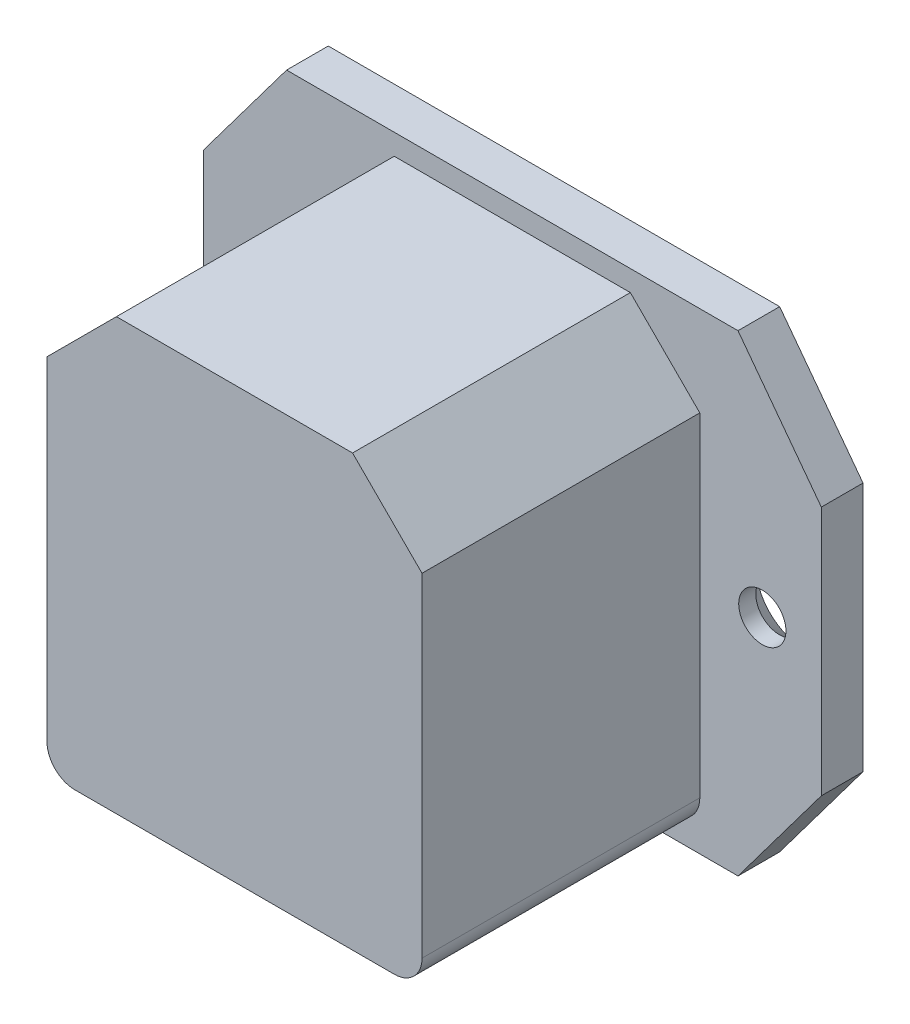
from build123d import *

# Parameters (mm, degrees)
SKIZZE1_W                                   = 27
SKIZZE1_H                                   = 31
AUFSATZ_LINEAR_AUSTRAGEN1_DEPTH             = 20
AUFSATZ_LINEAR_AUSTRAGEN2_DEPTH             = 3
FORMSENKUNG_F_R_M3_SENKSCHRAUBE_MIT_2_COUNT = 2
FORMSENKUNG_F_R_M3_SENKSCHRAUBE_MIT_2_PITCH = 36
SCHNITT_LINEAR_AUSTRAGEN1_DEPTH             = 18
FASE1_SIZE                                  = 5
VERRUNDUNG1_R                               = 2


with BuildPart() as part:
    # Skizze1 → Aufsatz-Linear austragen1 (new body)
    with BuildSketch(Plane.XY):
        Rectangle(SKIZZE1_W, SKIZZE1_H)
    extrude(amount=AUFSATZ_LINEAR_AUSTRAGEN1_DEPTH)

    # Skizze2 → Aufsatz-Linear austragen2 (add)
    with BuildSketch(Plane.XY):
        Polygon((16.25, 17), (-16.25, 17), (-22.25, 9), (-22.25, -9), (-16.25, -17), (16.25, -17), (22.25, -9), (22.25, 9), align=None)
    extrude(amount=-AUFSATZ_LINEAR_AUSTRAGEN2_DEPTH)

    # Skizze3 → Formsenkung für M3 Senkschraube mit Innensechskant1 (revolve, cut)
    with BuildSketch(Plane(origin=(18, 0, -3), x_dir=(0, 1, 0), z_dir=(1, 0, 0))):
        Polygon((0, 0), (0, 3), (1.7, 3), (1.7, 1.77), (3.47, 0), align=None)
    formsenkung_f_r_m3_senkschraube_mit_inne = revolve(axis=Axis((18, 0, -9.35), (0, 0, 1)), mode=Mode.SUBTRACT)

    # Formsenkung f_r M3 Senkschraube mit  2: Formsenkung für M3 Senkschraube mit Innensechskant1 ×2
    with Locations(*[(-i * FORMSENKUNG_F_R_M3_SENKSCHRAUBE_MIT_2_PITCH, 0, 0) for i in range(1, FORMSENKUNG_F_R_M3_SENKSCHRAUBE_MIT_2_COUNT)]):
        add(formsenkung_f_r_m3_senkschraube_mit_inne, mode=Mode.SUBTRACT)

    # Skizze5 → Schnitt-Linear austragen1 (cut)
    with BuildSketch(Plane(origin=(0, 0, -3), x_dir=(-1, 0, 0), z_dir=(0, 0, -1))):
        Polygon((7.25, 14), (-7.25, 14), (-12.25, 9), (-12.25, -2), (12.25, -2), (12.25, 9), align=None)
    extrude(amount=-SCHNITT_LINEAR_AUSTRAGEN1_DEPTH, mode=Mode.SUBTRACT)

    # Fase1
    fase1_edges = [part.edges().sort_by_distance(p)[0] for p in [
        (-13.5, 15.5, 10),
        (13.5, 15.5, 10),
    ]]
    chamfer(fase1_edges, length=FASE1_SIZE)

    # Verrundung1
    verrundung1_edges = [part.edges().sort_by_distance(p)[0] for p in [
        (13.5, -15.5, 10),
        (-13.5, -15.5, 10),
    ]]
    fillet(verrundung1_edges, radius=VERRUNDUNG1_R)


solid = part.part
